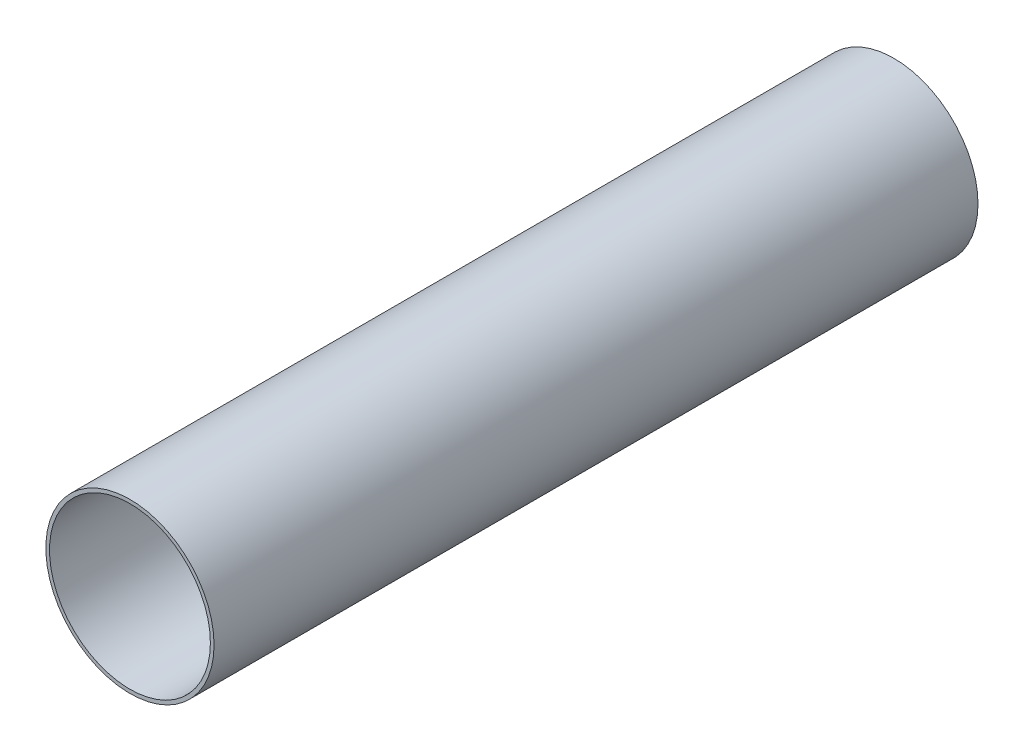
from build123d import *

# Parameters (mm, degrees)
SKETCH1_R           = 28.625
BOSS_EXTRUDE1_DEPTH = 260
CUT_EXTRUDE1_REACH  = 262
SKETCH2_R           = 27.375


with BuildPart() as part:
    # Sketch1 → Boss-Extrude1 (new body)
    with BuildSketch(Plane.XY):
        Circle(SKETCH1_R)
    extrude(amount=-BOSS_EXTRUDE1_DEPTH)

    # Sketch2 → Cut-Extrude1 (cut, up to next)
    with BuildSketch(Plane.XY, mode=Mode.PRIVATE) as cut_extrude1_sk1:
        Circle(SKETCH2_R)
    cut_extrude1_tool1 = extrude(cut_extrude1_sk1.sketch, amount=-CUT_EXTRUDE1_REACH, mode=Mode.PRIVATE) & part.part
    add(cut_extrude1_tool1.solids().sort_by_distance((0, 0, 0))[0], mode=Mode.SUBTRACT)


solid = part.part
